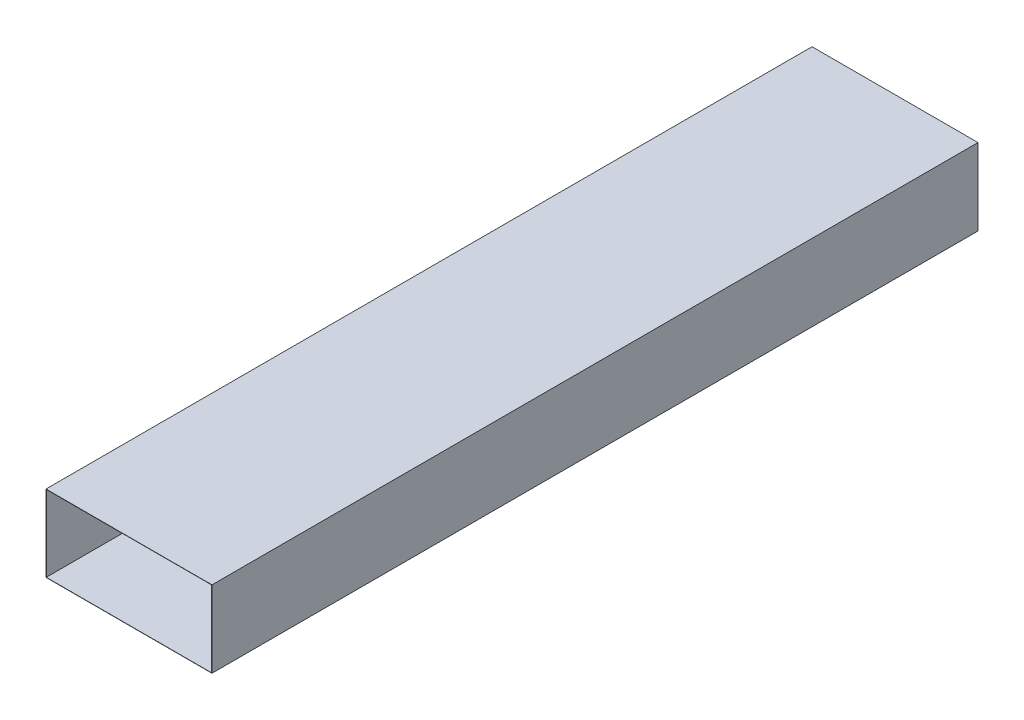
from build123d import *

# Parameters (mm, degrees)
SKETCH1_W           = 650
SKETCH1_H           = 300
SKETCH1_W_2         = 648
SKETCH1_H_2         = 298
EXTRUDE_THIN1_DEPTH = 3000


with BuildPart() as part:
    # Sketch1 → Extrude-Thin1 (new body)
    with BuildSketch(Plane.XY):
        with Locations((-325, 150)):
            Rectangle(SKETCH1_W, SKETCH1_H)
        with Locations((-325, 150)):
            Rectangle(SKETCH1_W_2, SKETCH1_H_2, mode=Mode.SUBTRACT)
    extrude(amount=EXTRUDE_THIN1_DEPTH)


solid = part.part
